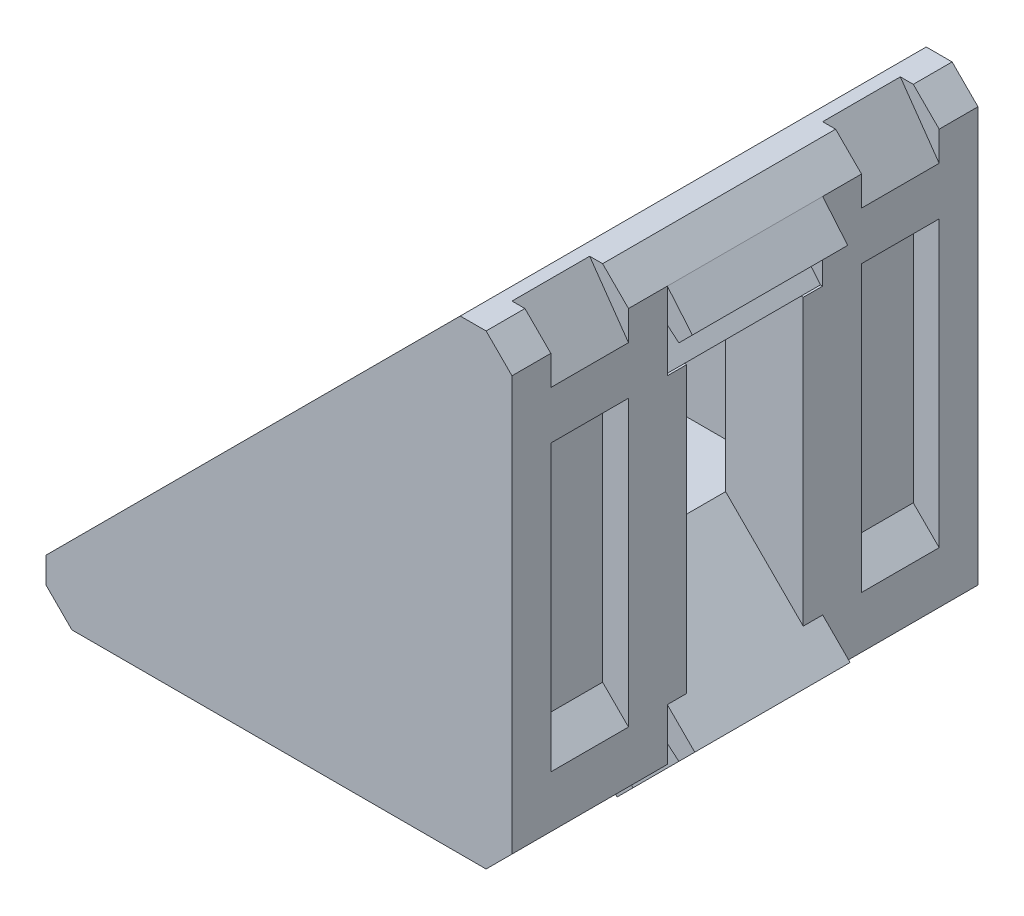
from build123d import *

# Parameters (mm, degrees)
EXTRUDE_1_DEPTH     = 6
EXTRUDE_1_2_DEPTH   = 6
EXTRUDE_1_3_DEPTH   = 6
EXTRUDE_2_DEPTH     = 4
EXTRUDE_3_DEPTH     = 2
EXTRUDE_4_DEPTH     = 0.75
EXTRUDE_5_DEPTH     = 0.75
CUT_EXTRUDE_2_DEPTH = 3
CUT_EXTRUDE_3_DEPTH = 3
CUT_EXTRUDE_4_DEPTH = 3
CUT_EXTRUDE_5_DEPTH = 3
CHAMFER_1_SIZE      = 1


with BuildPart() as part:
    # 草图1 → 拉伸1 (new body)
    with BuildSketch(Plane.XY):
        Polygon((32.591759834, 56.594303521), (33.206070874, 57.208614562), (29.145410702, 61.269274733), (29.145410702, 58.269274733), (26.145410702, 58.269274733), (30.206070874, 54.208614562), (30.820381914, 54.822925602), (29.852517484, 55.976381515), (31.438303921, 57.562167952), align=None)
    extrude(amount=EXTRUDE_1_DEPTH)



with BuildPart() as body_2:
    # 草图1 → Extrude 1 2 (new body)
    with BuildSketch(Plane.XY):
        Polygon((18.145410702, 55.352855481), (18.145410702, 58.269274733), (15.145410702, 58.269274733), (14.145410702, 57.269274733), (14.145410702, 56.269274733), (15.145410702, 55.269274733), (16.298866615, 54.301410302), (16.820381914, 54.822925602), (15.852517484, 55.976381515), (16.559624265, 56.683488296), align=None)
    extrude(amount=EXTRUDE_1_2_DEPTH)


with BuildPart() as body_3:
    # 草图1 → Extrude 1 3 (new body)
    with BuildSketch(Plane.XY):
        Polygon((31.438303921, 71.562167952), (32.591759834, 70.594303521), (33.113275133, 71.115818821), (32.145410702, 72.269274733), (31.145410702, 73.269274733), (30.145410702, 73.269274733), (29.145410702, 72.269274733), (29.145410702, 69.269274733), (32.061829955, 69.269274733), (30.73119714, 70.855061171), align=None)
    extrude(amount=EXTRUDE_1_3_DEPTH)


with BuildPart() as part_1:
    add(part.part)

    add(body_2.part)  # 拉伸2 merges body 2

    add(body_3.part)  # 拉伸2 merges body 3
    # 草图2 → 拉伸2 (add)
    with BuildSketch(Plane.XY.offset(6)):
        Polygon((30.145410702, 73.269274733), (31.145410702, 73.269274733), (32.145410702, 72.269274733), (32.145410702, 55.269274733), (15.145410702, 55.269274733), (14.145410702, 56.269274733), (14.145410702, 57.269274733), (15.145410702, 58.269274733), (29.145410702, 58.269274733), (29.145410702, 72.269274733), align=None)
    extrude_2 = extrude(amount=EXTRUDE_2_DEPTH)

    # 镜向1: 拉伸2 across plane
    add(extrude_2.mirror(Plane(origin=(0, 0, 3), x_dir=(1, 0, 0), z_dir=(0, 0, -1))))

    # 草图3 → 拉伸3 (add)
    with BuildSketch(Plane.XY.offset(10)):
        Polygon((30.145410702, 73.269274733), (31.145410702, 73.269274733), (32.145410702, 72.269274733), (32.145410702, 55.269274733), (15.145410702, 55.269274733), (14.145410702, 56.269274733), (14.145410702, 57.269274733), align=None)
    extrude_3 = extrude(amount=EXTRUDE_3_DEPTH)

    # 镜向2: 拉伸3 across plane
    add(extrude_3.mirror(Plane(origin=(0, 0, 3), x_dir=(1, 0, 0), z_dir=(0, 0, -1))))

    # 草图4 → 拉伸4 (add)
    with BuildSketch(Plane.XY):
        Polygon((29.145410702, 69.269274733), (32.145410702, 69.269274733), (32.145410702, 58.269274733), (29.145410702, 61.269274733), align=None)
    extrude_4 = extrude(amount=EXTRUDE_4_DEPTH)

    # 镜向3: 拉伸4 across plane
    add(extrude_4.mirror(Plane(origin=(0, 0, 3), x_dir=(1, 0, 0), z_dir=(0, 0, -1))))

    # 草图5 → 拉伸5 (add)
    with BuildSketch(Plane.XY):
        Polygon((26.145410702, 58.269274733), (18.145410702, 58.269274733), (18.145410702, 55.269274733), (29.145410702, 55.269274733), align=None)
    extrude_5 = extrude(amount=EXTRUDE_5_DEPTH)

    # 镜向4: 拉伸5 across plane
    add(extrude_5.mirror(Plane(origin=(0, 0, 3), x_dir=(1, 0, 0), z_dir=(0, 0, -1))))

    # 草图7 → 切除-拉伸2 (cut)
    with BuildSketch(Plane(origin=(0, 0, -4.5), x_dir=(-1, 0, 0), z_dir=(0, 0, -1))):
        Polygon((-32.145410702, 69.269274733), (-31.145410702, 69.269274733), (-31.145410702, 59.269274733), (-32.145410702, 58.269274733), align=None)
    cut_extrude_2 = extrude(amount=-CUT_EXTRUDE_2_DEPTH, mode=Mode.SUBTRACT)

    # 草图8 → 切除-拉伸3 (cut)
    with BuildSketch(Plane(origin=(0, 0, -4.5), x_dir=(-1, 0, 0), z_dir=(0, 0, -1))):
        Polygon((-18.145410702, 55.269274733), (-18.145410702, 56.269274733), (-28.145410702, 56.269274733), (-29.145410702, 55.269274733), align=None)
    cut_extrude_3 = extrude(amount=-CUT_EXTRUDE_3_DEPTH, mode=Mode.SUBTRACT)

    # 镜向5: 切除-拉伸2, 切除-拉伸3 across plane
    add(cut_extrude_2.mirror(Plane(origin=(0, 0, 3), x_dir=(1, 0, 0), z_dir=(0, 0, -1))), mode=Mode.SUBTRACT)
    add(cut_extrude_3.mirror(Plane(origin=(0, 0, 3), x_dir=(1, 0, 0), z_dir=(0, 0, -1))), mode=Mode.SUBTRACT)

    # 草图9 → 切除-拉伸4 (cut)
    with BuildSketch(Plane(origin=(0, 0, -4.5), x_dir=(-1, 0, 0), z_dir=(0, 0, -1))):
        Polygon((-30.645410702, 73.269274733), (-32.145410702, 71.127052723), (-32.145410702, 72.269274733), (-31.145410702, 73.269274733), align=None)
    cut_extrude_4 = extrude(amount=-CUT_EXTRUDE_4_DEPTH, mode=Mode.SUBTRACT)

    # 草图10 → 切除-拉伸5 (cut)
    with BuildSketch(Plane(origin=(0, 0, -4.5), x_dir=(-1, 0, 0), z_dir=(0, 0, -1))):
        Polygon((-14.145410702, 56.769274733), (-16.287632713, 55.269274733), (-15.145410702, 55.269274733), (-14.145410702, 56.269274733), align=None)
    cut_extrude_5 = extrude(amount=-CUT_EXTRUDE_5_DEPTH, mode=Mode.SUBTRACT)

    # 镜向6: 切除-拉伸4, 切除-拉伸5 across plane
    add(cut_extrude_4.mirror(Plane(origin=(0, 0, 3), x_dir=(1, 0, 0), z_dir=(0, 0, -1))), mode=Mode.SUBTRACT)
    add(cut_extrude_5.mirror(Plane(origin=(0, 0, 3), x_dir=(1, 0, 0), z_dir=(0, 0, -1))), mode=Mode.SUBTRACT)

    # 倒角1
    chamfer_1_edges = [part_1.edges().sort_by_distance(p)[0] for p in [
        (32.145410702, 55.269274733, -3),
        (32.145410702, 55.269274733, 9),
    ]]
    chamfer(chamfer_1_edges, length=CHAMFER_1_SIZE)


solid = part_1.part
